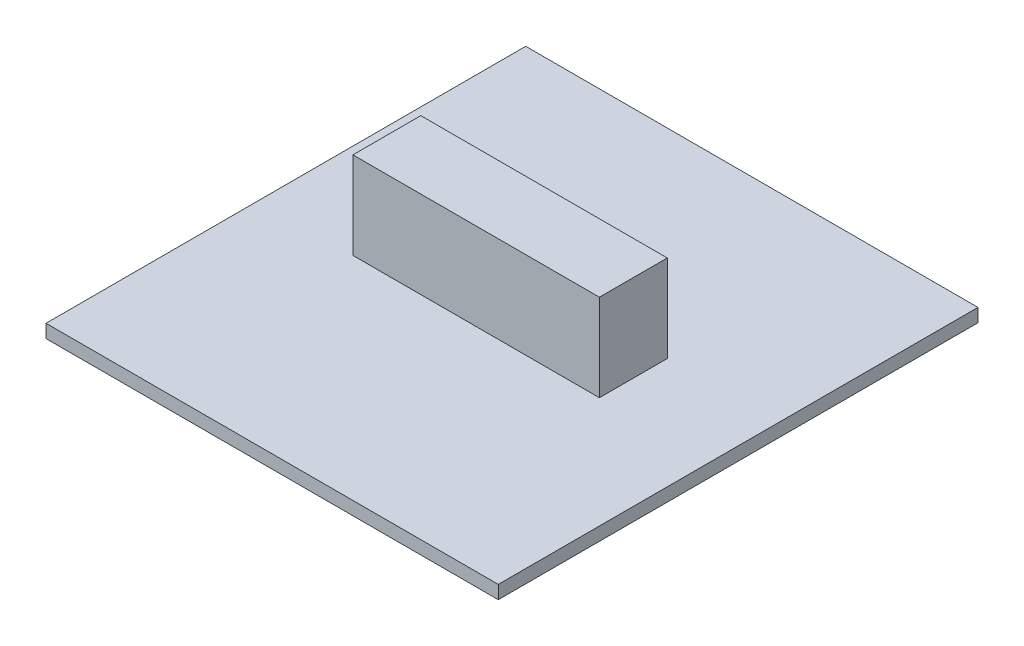
from build123d import *

# Parameters (mm, degrees)
SKETCH1_W           = 77.8256
SKETCH1_H           = 82.55
BOSS_EXTRUDE2_DEPTH = 2.286
SKETCH2_W           = 42.414253103
SKETCH2_H           = 11.682567677
BOSS_EXTRUDE3_DEPTH = 14.986


with BuildPart() as part:
    # Sketch1 → Boss-Extrude2 (new body)
    with BuildSketch(Plane(origin=(0, 0, 0), x_dir=(1, 0, 0), z_dir=(0, 1, 0))):
        with Locations((38.9128, -41.275)):
            Rectangle(SKETCH1_W, SKETCH1_H)
    extrude(amount=BOSS_EXTRUDE2_DEPTH)

    # Sketch2 → Boss-Extrude3 (add)
    with BuildSketch(Plane(origin=(0, 2.286, 0), x_dir=(1, 0, 0), z_dir=(0, 1, 0))):
        with Locations((37.503184862, -40.192722516)):
            Rectangle(SKETCH2_W, SKETCH2_H)
    extrude(amount=BOSS_EXTRUDE3_DEPTH)


solid = part.part
